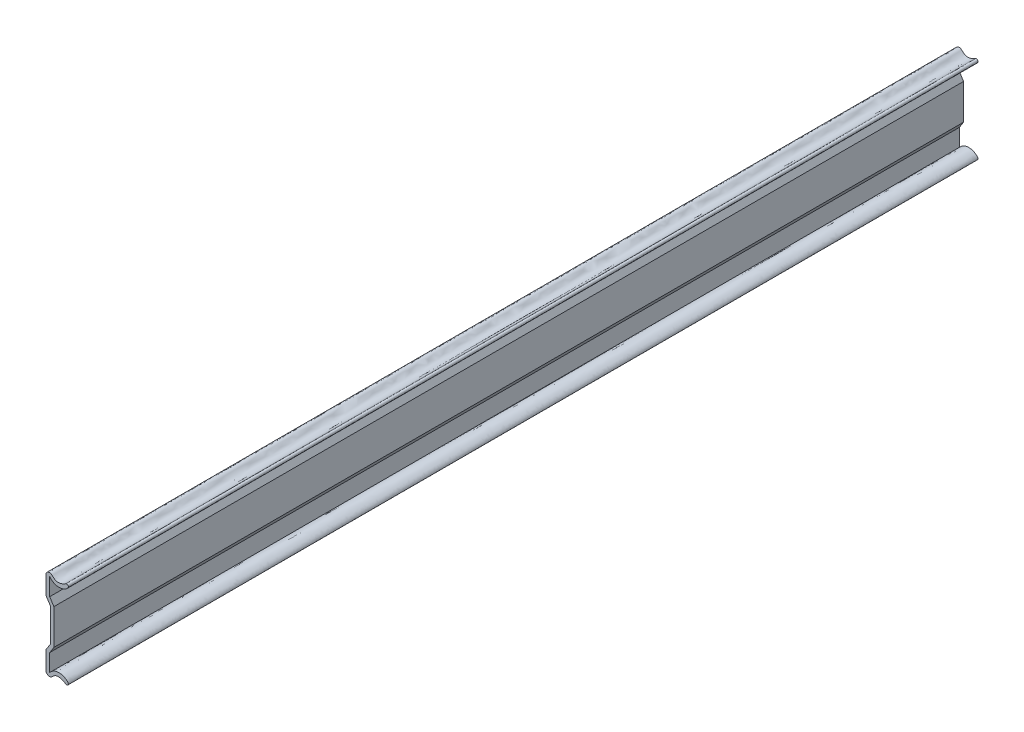
from build123d import *

# Parameters (mm, degrees)
BOSS_EXTRUDE1_DEPTH = 346


with BuildPart() as part:
    # Sketch1 → Boss-Extrude1 (new body)
    with BuildSketch(Plane.XY):
        with BuildLine():
            Line((3.998128431, 3930.19429763), (3.998128431, 3942.61393117))
            Line((3.998128431, 3942.61393117), (2.24716154, 3945.283540463))
            add(Edge.make_bspline(
                [(2.24716154, 3945.283540463), (2.24716154, 3952.005320214), (2.232364081, 3952.64476798), (2.418534613, 3952.931300145), (2.437330297, 3952.953993873), (2.644913472, 3953.189193699), (2.985745197, 3953.397331776), (3.474090119, 3953.514910023), (3.621593384, 3953.523890776), (4.047760205, 3953.46923312), (4.58125793, 3953.187406687), (5.083187742, 3952.608694393), (5.554338839, 3952.255739055), (5.72807197, 3952.152608867), (6.316517593, 3951.924297186), (6.791285846, 3951.872127026), (7.588079693, 3951.972971408), (7.870693848, 3952.038510337), (8.716179179, 3952.307047358), (9.270874628, 3952.577817288), (9.633463159, 3952.847687913)],
                knots=[0, 0, 0, 0, 0.15625, 0.15625, 0.171875, 0.171875, 0.3125, 0.3125, 0.375, 0.375, 0.5, 0.625, 0.625, 0.6875, 0.6875, 0.8125, 0.8125, 0.875, 0.875, 1, 1, 1, 1], degree=3))
            add(Edge.make_bspline(
                [(9.633463159, 3952.847687913), (10.417946549, 3953.431570206), (11.567668705, 3952.354694242), (9.785383498, 3951.25308009), (9.778595571, 3951.248908712), (9.024795297, 3950.786457422), (8.453268543, 3950.557423937), (7.530150442, 3950.453852262), (7.250375188, 3950.447650833), (6.015693334, 3950.517530338), (4.860141708, 3950.826642053), (3.661404029, 3952.195277246)],
                knots=[0, 0, 0, 0, 0.188476563, 0.188476563, 0.188964844, 0.188964844, 0.5, 0.5, 0.625, 0.625, 1, 1, 1, 1], degree=3))
            Line((3.661404029, 3952.195277246), (3.661404029, 3945.606734335))
            Line((3.661404029, 3945.606734335), (5.239324609, 3943.119425521))
            Line((5.239324609, 3943.119425521), (5.239324609, 3929.688803279))
            Line((5.239324609, 3929.688803279), (3.661404029, 3927.201494466))
            Line((3.661404029, 3927.201494466), (3.661404029, 3920.612951555))
            add(Edge.make_bspline(
                [(3.661404029, 3920.612951555), (4.860141708, 3921.981586748), (6.015693334, 3922.290698463), (7.250375188, 3922.360577968), (7.530150442, 3922.354376539), (8.453268543, 3922.250804863), (9.024795297, 3922.021771379), (9.778595571, 3921.559320088), (9.785383498, 3921.555148711), (11.567668705, 3920.453534559), (10.417946549, 3919.376658594), (9.633463159, 3919.960540887)],
                knots=[0, 0, 0, 0, 0.375, 0.375, 0.5, 0.5, 0.811035156, 0.811035156, 0.811523437, 0.811523437, 1, 1, 1, 1], degree=3))
            add(Edge.make_bspline(
                [(9.633463159, 3919.960540887), (9.270874628, 3920.230411512), (8.716179179, 3920.501181443), (7.870693848, 3920.769718464), (7.588079693, 3920.835257393), (6.791285846, 3920.936101775), (6.316517593, 3920.883931614), (5.72807197, 3920.655619933), (5.554338839, 3920.552489745), (5.083187742, 3920.199534408), (4.58125793, 3919.620822113), (4.047760205, 3919.33899568), (3.621593384, 3919.284338025), (3.474090119, 3919.293318777), (2.985745197, 3919.410897024), (2.644913472, 3919.619035102), (2.437330297, 3919.854234927), (2.418534613, 3919.876928656), (2.232364081, 3920.163460821), (2.24716154, 3920.802908586), (2.24716154, 3927.524688337)],
                knots=[0, 0, 0, 0, 0.125, 0.125, 0.1875, 0.1875, 0.3125, 0.3125, 0.375, 0.375, 0.5, 0.625, 0.625, 0.6875, 0.6875, 0.828125, 0.828125, 0.84375, 0.84375, 1, 1, 1, 1], degree=3))
            Line((2.24716154, 3927.524688337), (3.998128431, 3930.19429763))
        make_face()
    extrude(amount=BOSS_EXTRUDE1_DEPTH)


solid = part.part
